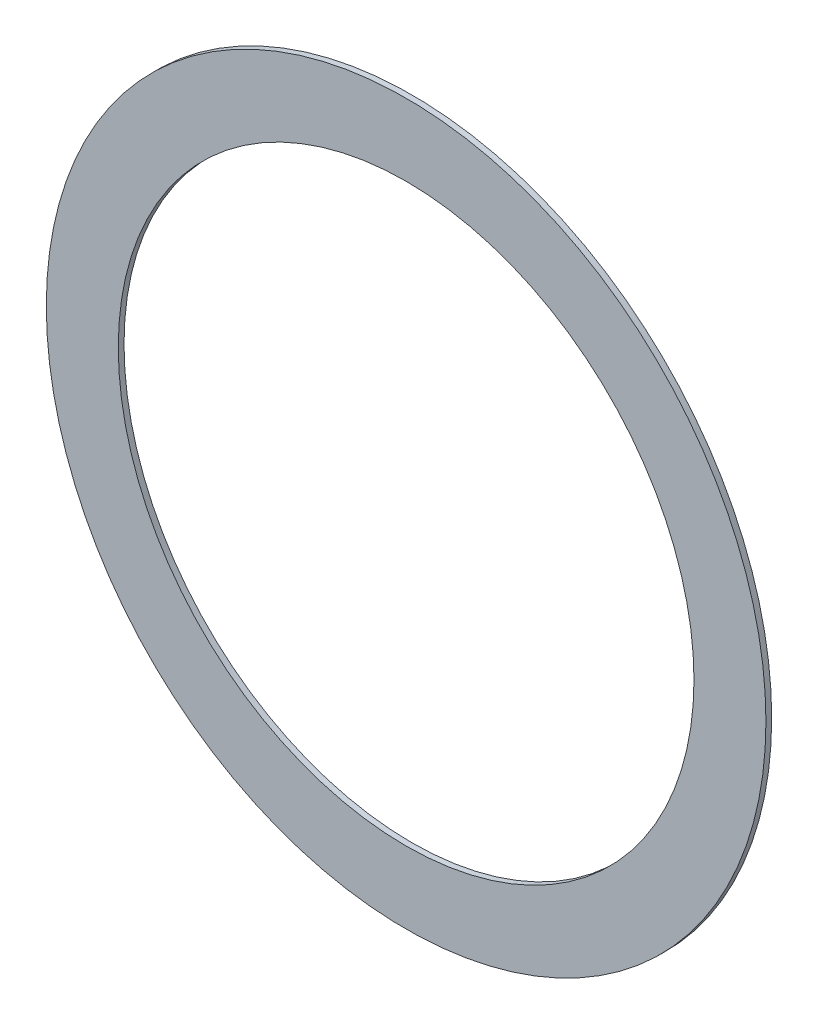
from build123d import *

# Parameters (mm, degrees)
SKIZZE1_8_R                     = 6.25
SKIZZE1_8_R_2                   = 5
AUFSATZ_LINEAR_AUSTRAGEN3_DEPTH = 0.1


with BuildPart() as part:
    # Skizze1_8 → Aufsatz-Linear austragen3 (new body)
    with BuildSketch(Plane.XY):
        Circle(SKIZZE1_8_R)
        Circle(SKIZZE1_8_R_2, mode=Mode.SUBTRACT)
    extrude(amount=AUFSATZ_LINEAR_AUSTRAGEN3_DEPTH)


solid = part.part
